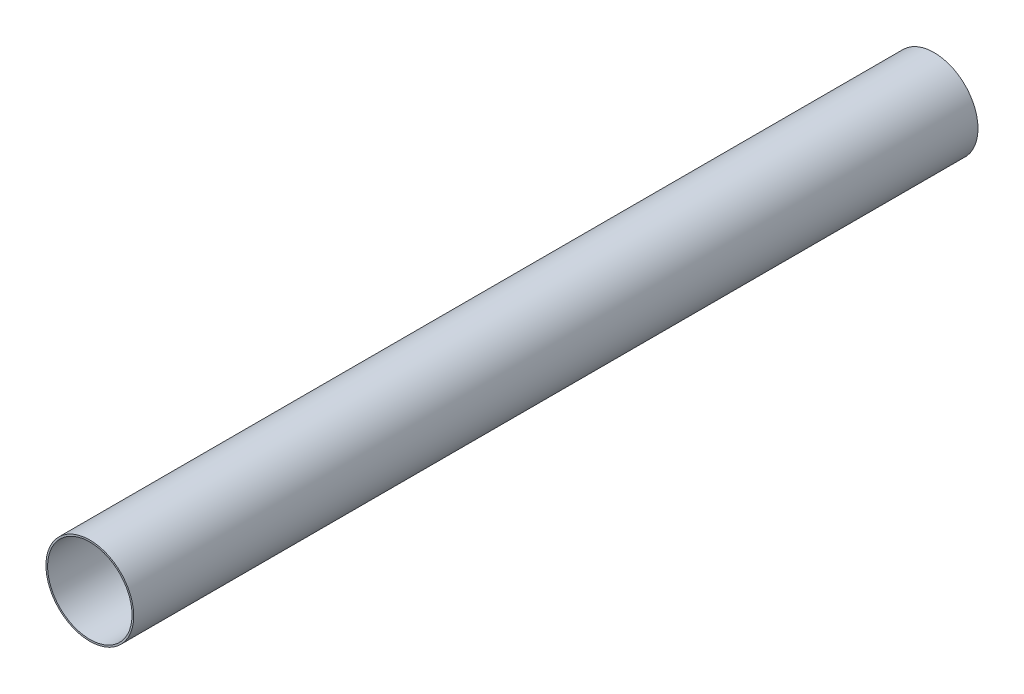
from build123d import *

# Parameters (mm, degrees)
ESQUISSE_DE_TUYAU_R   = 52
ESQUISSE_DE_TUYAU_R_2 = 50
EXTRUSION_DEPTH       = 1000


with BuildPart() as part:
    # Esquisse de tuyau → Extrusion (new body)
    with BuildSketch(Plane.XY):
        Circle(ESQUISSE_DE_TUYAU_R)
        Circle(ESQUISSE_DE_TUYAU_R_2, mode=Mode.SUBTRACT)
    extrude(amount=EXTRUSION_DEPTH)


solid = part.part
